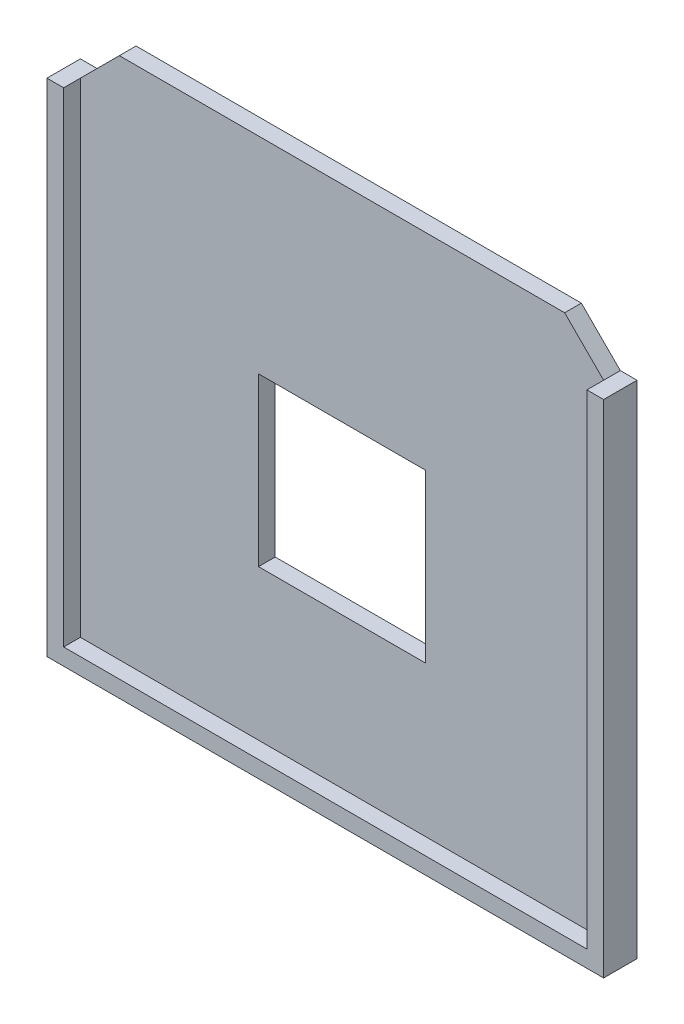
from build123d import *

# Parameters (mm, degrees)
SALIENTE_EXTRUIR1_DEPTH = 3
CROQUIS3_W              = 30
CROQUIS3_H              = 30
CORTAR_EXTRUIR1_DEPTH   = 3
SALIENTE_EXTRUIR2_DEPTH = 3


with BuildPart() as part:
    # Croquis1 → Saliente-Extruir1 (new body)
    with BuildSketch(Plane.XY):
        Polygon((-50, 45), (-47, 45), (-40, 52), (40, 52), (47, 45), (50, 45), (50, -45), (-50, -45), align=None)
    extrude(amount=SALIENTE_EXTRUIR1_DEPTH)

    # Croquis3 → Cortar-Extruir1 (cut)
    with BuildSketch(Plane.XY.offset(3)):
        Rectangle(CROQUIS3_W, CROQUIS3_H)
    extrude(amount=-CORTAR_EXTRUIR1_DEPTH, mode=Mode.SUBTRACT)

    # Croquis4 → Saliente-Extruir2 (add)
    with BuildSketch(Plane.XY.offset(3)):
        Polygon((-50, 45), (-47, 45), (-47, -42), (47, -42), (47, 45), (50, 45), (50, -45), (-50, -45), align=None)
    extrude(amount=SALIENTE_EXTRUIR2_DEPTH)


solid = part.part
